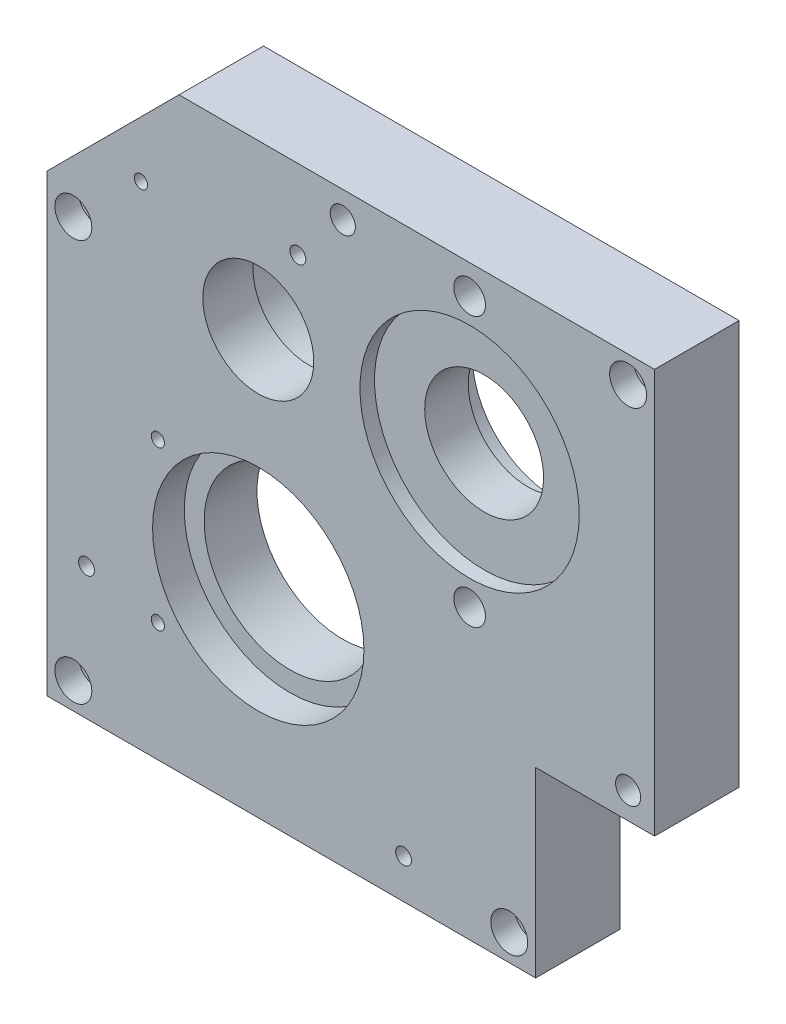
from build123d import *

# Parameters (mm, degrees)
EXTRUDE_1_DEPTH          = 32
SKETCH_3_R               = 40
CUT_EXTRUDE_1_DEPTH      = 12
SKETCH_4_R               = 32.5
CUT_EXTRUDE_2_DEPTH      = 113
SKETCH_5_R               = 23.5
CUT_EXTRUDE_3_DEPTH      = 13
SKETCH_6_R               = 21
CUT_EXTRUDE_4_DEPTH      = 113
SKETCH_7_R               = 22.5
CUT_EXTRUDE_5_DEPTH      = 40
SKETCH_8_R               = 41.5
CUT_EXTRUDE_6_DEPTH      = 5.5
SKETCH_9_R               = 31
CUT_EXTRUDE_7_DEPTH      = 10
SKETCH_10_R              = 2.5
CUT_EXTRUDE_8_DEPTH      = 18
PATTERN_CIRCULAR_1_COUNT = 4
SKETCH_12_W              = 185
SKETCH_12_H              = 5
CUT_EXTRUDE_10_DEPTH     = 114
SKETCH_13_R              = 6
CUT_EXTRUDE_11_DEPTH     = 14
SKETCH_14_R              = 4
SKETCH_14_R_2            = 4.76
CUT_EXTRUDE_12_DEPTH     = 96
SKETCH_15_R              = 7
CUT_EXTRUDE_13_DEPTH     = 9
SKETCH_16_R              = 2.531047244
SKETCH_16_R_2            = 3
CUT_EXTRUDE_14_DEPTH     = 10
SKETCH_17_R              = 2.5
CUT_EXTRUDE_15_DEPTH     = 8


with BuildPart() as part:
    # 草图1 → 凸台-拉伸1 (new body)
    with BuildSketch(Plane.XY):
        Polygon((105, -80), (105, -6), (150, -6), (150, 147), (-30, 147), (-80, 97), (-80, -80), align=None)
    extrude(amount=EXTRUDE_1_DEPTH)

    # 草图3 → 切除-拉伸1 (cut)
    with BuildSketch(Plane.XY.offset(32)):
        Circle(SKETCH_3_R)
    extrude(amount=-CUT_EXTRUDE_1_DEPTH, mode=Mode.SUBTRACT)

    # 草图4 → 切除-拉伸2 (cut)
    with BuildSketch(Plane.XY.offset(20)):
        Circle(SKETCH_4_R)
    extrude(amount=-CUT_EXTRUDE_2_DEPTH, mode=Mode.SUBTRACT)

    # 草图5 → 切除-拉伸3 (cut)
    with BuildSketch(Plane(origin=(0, 0, 0), x_dir=(-1, 0, 0), z_dir=(0, 0, -1))):
        with Locations((0, 85)):
            Circle(SKETCH_5_R)
    extrude(amount=-CUT_EXTRUDE_3_DEPTH, mode=Mode.SUBTRACT)

    # 草图6 → 切除-拉伸4 (cut)
    with BuildSketch(Plane(origin=(0, 0, 13), x_dir=(-1, 0, 0), z_dir=(0, 0, -1))):
        with Locations((0, 85)):
            Circle(SKETCH_6_R)
    extrude(amount=-CUT_EXTRUDE_4_DEPTH, mode=Mode.SUBTRACT)

    # 草图7 → 切除-拉伸5 (cut)
    with BuildSketch(Plane(origin=(0, 0, 0), x_dir=(-1, 0, 0), z_dir=(0, 0, -1))):
        with Locations((-80, 85)):
            Circle(SKETCH_7_R)
    extrude(amount=-CUT_EXTRUDE_5_DEPTH, mode=Mode.SUBTRACT)

    # 草图8 → 切除-拉伸6 (cut)
    with BuildSketch(Plane.XY.offset(32)):
        with Locations((80, 85)):
            Circle(SKETCH_8_R)
    extrude(amount=-CUT_EXTRUDE_6_DEPTH, mode=Mode.SUBTRACT)

    # 草图9 → 切除-拉伸7 (cut)
    with BuildSketch(Plane(origin=(0, 0, 0), x_dir=(-1, 0, 0), z_dir=(0, 0, -1))):
        with Locations((-80, 85)):
            Circle(SKETCH_9_R)
    extrude(amount=-CUT_EXTRUDE_7_DEPTH, mode=Mode.SUBTRACT)

    # 草图10 → 切除-拉伸8 (cut)
    with BuildSketch(Plane(origin=(0, 0, 0), x_dir=(-1, 0, 0), z_dir=(0, 0, -1))):
        with Locations((-41, 85)):
            Circle(SKETCH_10_R)
    cut_extrude_8 = extrude(amount=-CUT_EXTRUDE_8_DEPTH, mode=Mode.SUBTRACT)

    # 阵列(圆周)1: 切除-拉伸8 ×4 about axis
    pattern_circular_1_axis = Axis((80, 85, 0), (0, 0, 1))
    for i in range(1, PATTERN_CIRCULAR_1_COUNT):
        add(cut_extrude_8.rotate(pattern_circular_1_axis, i * 360 / PATTERN_CIRCULAR_1_COUNT), mode=Mode.SUBTRACT)

    # 草图12 → 切除-拉伸10 (cut)
    with BuildSketch(Plane(origin=(0, 0, 0), x_dir=(-1, 0, 0), z_dir=(0, 0, -1))):
        with Locations((-12.5, -77.5)):
            Rectangle(SKETCH_12_W, SKETCH_12_H)
    extrude(amount=-CUT_EXTRUDE_10_DEPTH, mode=Mode.SUBTRACT)

    # 草图13 → 切除-拉伸11 (cut)
    with BuildSketch(Plane.XY.offset(32)):
        with Locations((80, 34)):
            Circle(SKETCH_13_R)
        with Locations((80, 136)):
            Circle(SKETCH_13_R)
    extrude(amount=-CUT_EXTRUDE_11_DEPTH, mode=Mode.SUBTRACT)

    # 草图14 → 切除-拉伸12 (cut)
    with BuildSketch(Plane.XY.offset(32)):
        with Locations((140, 137)):
            Circle(SKETCH_14_R)
        with Locations((140, 4)):
            Circle(SKETCH_14_R_2)
        with Locations((32, 137)):
            Circle(SKETCH_14_R_2)
        with Locations((-70, -65)):
            Circle(SKETCH_14_R)
        with Locations((95, -65)):
            Circle(SKETCH_14_R)
        with Locations((-70, 87)):
            Circle(SKETCH_14_R)
    extrude(amount=-CUT_EXTRUDE_12_DEPTH, mode=Mode.SUBTRACT)

    # 草图15 → 切除-拉伸13 (cut)
    with BuildSketch(Plane.XY.offset(32)):
        with Locations((140, 137)):
            Circle(SKETCH_15_R)
        with Locations((95, -65)):
            Circle(SKETCH_15_R)
        with Locations((-70, -65)):
            Circle(SKETCH_15_R)
        with Locations((-70, 87)):
            Circle(SKETCH_15_R)
    extrude(amount=-CUT_EXTRUDE_13_DEPTH, mode=Mode.SUBTRACT)

    # 草图16 → 切除-拉伸14 (cut)
    with BuildSketch(Plane.XY.offset(32)):
        with Locations((-44.393398282, 111.393398282)):
            Circle(SKETCH_16_R)
        with Locations((55, -60)):
            Circle(SKETCH_16_R_2)
        with Locations((-65, -25)):
            Circle(SKETCH_16_R_2)
        with Locations((15, 117)):
            Circle(SKETCH_16_R_2)
    extrude(amount=-CUT_EXTRUDE_14_DEPTH, mode=Mode.SUBTRACT)

    # 草图17 → 切除-拉伸15 (cut)
    with BuildSketch(Plane.XY.offset(32)):
        with Locations((-38, 30)):
            Circle(SKETCH_17_R)
        with Locations((-38, -30)):
            Circle(SKETCH_17_R)
    extrude(amount=-CUT_EXTRUDE_15_DEPTH, mode=Mode.SUBTRACT)


solid = part.part
